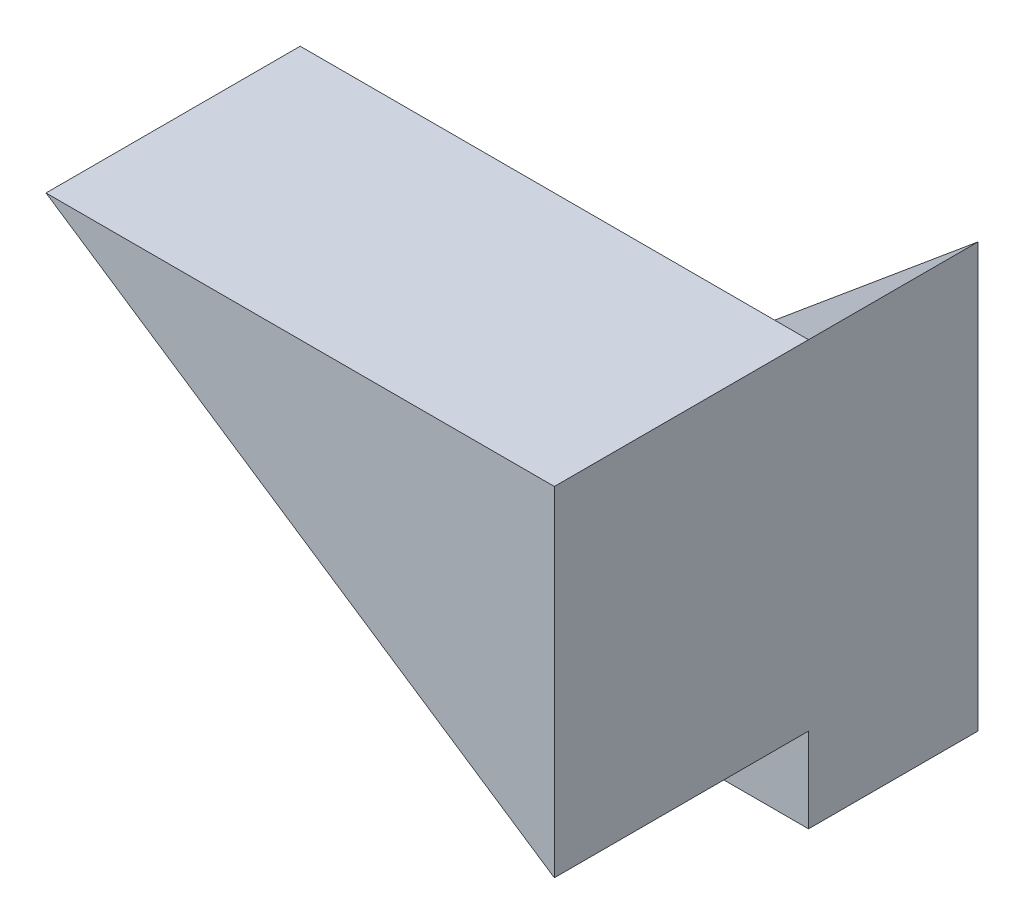
from build123d import *

# Parameters (mm, degrees)
BOSS_EXTRUDE1_DEPTH = 10
BOSS_EXTRUDE2_DEPTH = 15


with BuildPart() as part:
    # Sketch1 → Boss-Extrude1 (new body)
    with BuildSketch(Plane.XY):
        Polygon((0, 0), (0, 25), (-30, 0), align=None)
    extrude(amount=BOSS_EXTRUDE1_DEPTH)

    # Sketch2 → Boss-Extrude2 (add)
    with BuildSketch(Plane.XY.offset(10)):
        Polygon((-30, 25), (0, 25), (0, 5), align=None)
    extrude(amount=BOSS_EXTRUDE2_DEPTH)


solid = part.part
